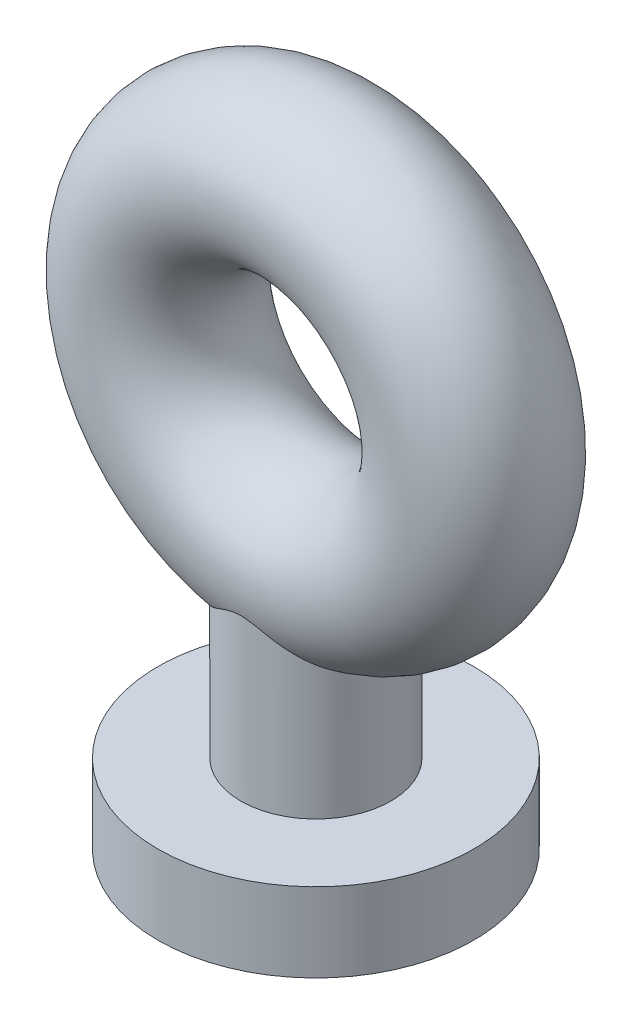
from build123d import *

# Parameters (mm, degrees)
SKETCH_1_R = 1


with BuildPart() as part:
    # 草图1 → 旋转1 (revolve)
    with BuildSketch(Plane(origin=(0, 0, 0), x_dir=(1, 0, 0), z_dir=(0, 1, 0))):
        with Locations((2, 0)):
            Circle(SKETCH_1_R)
    revolve(axis=Axis((0, 0, 0), (0, 0, 1)))

    # 草图2 → 旋转2 (revolve)
    with BuildSketch(Plane.XY):
        Polygon((0, -5.345610655), (0, -1.845610655), (0.95, -1.845610655), (0.95, -4.345610655), (2, -4.345610655), (2, -5.345610655), align=None)
    revolve(axis=Axis((0, 0, 0), (0, -1, 0)))


solid = part.part
